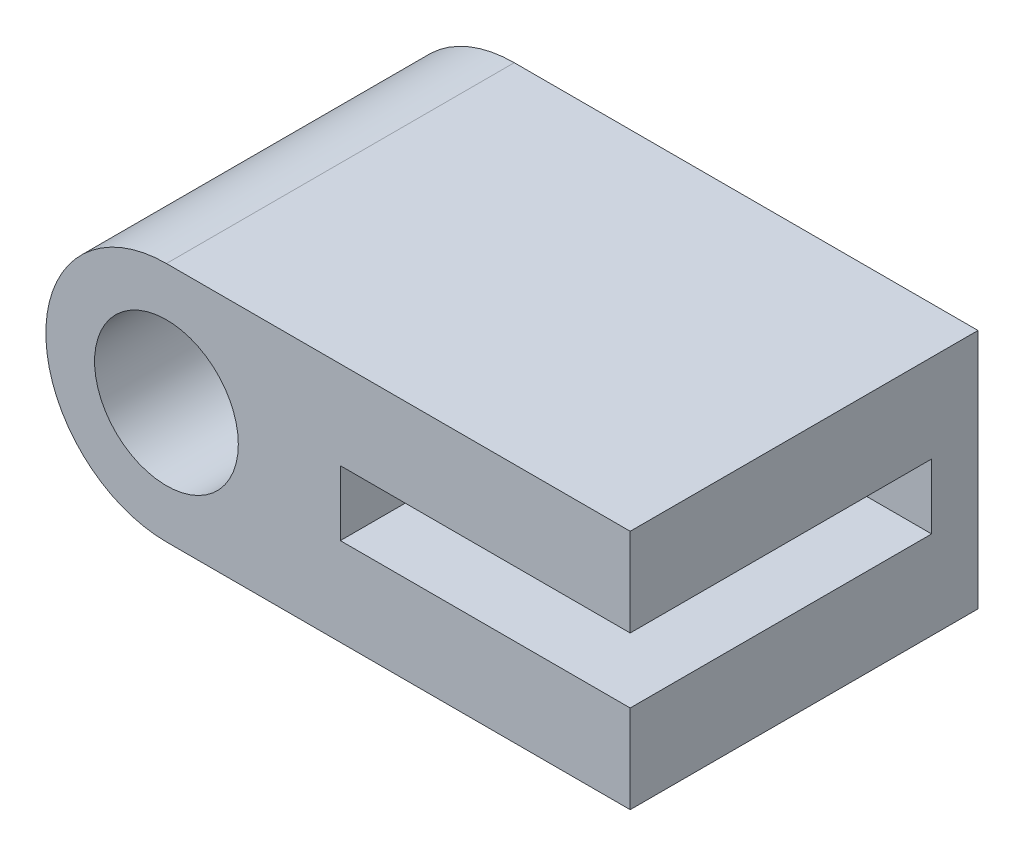
from build123d import *

# Parameters (mm, degrees)
CROQUIS1_R              = 3.1
SALIENTE_EXTRUIR1_DEPTH = 15
CROQUIS2_W              = 12.5
CROQUIS2_H              = 2.8
CORTAR_EXTRUIR1_DEPTH   = 13


with BuildPart() as part:
    # Croquis1 → Saliente-Extruir1 (new body)
    with BuildSketch(Plane.XY):
        with BuildLine():
            Line((0, 5.2), (20, 5.2))
            Line((20, 5.2), (20, -5.2))
            Line((20, -5.2), (0, -5.2))
            ThreePointArc((0, -5.2), (-5.2, 0), (0, 5.2))
        make_face()
        Circle(CROQUIS1_R, mode=Mode.SUBTRACT)
    extrude(amount=SALIENTE_EXTRUIR1_DEPTH)

    # Croquis2 → Cortar-Extruir1 (cut)
    with BuildSketch(Plane.XY.offset(15)):
        with Locations((13.75, 0)):
            Rectangle(CROQUIS2_W, CROQUIS2_H)
    extrude(amount=-CORTAR_EXTRUIR1_DEPTH, mode=Mode.SUBTRACT)


solid = part.part
